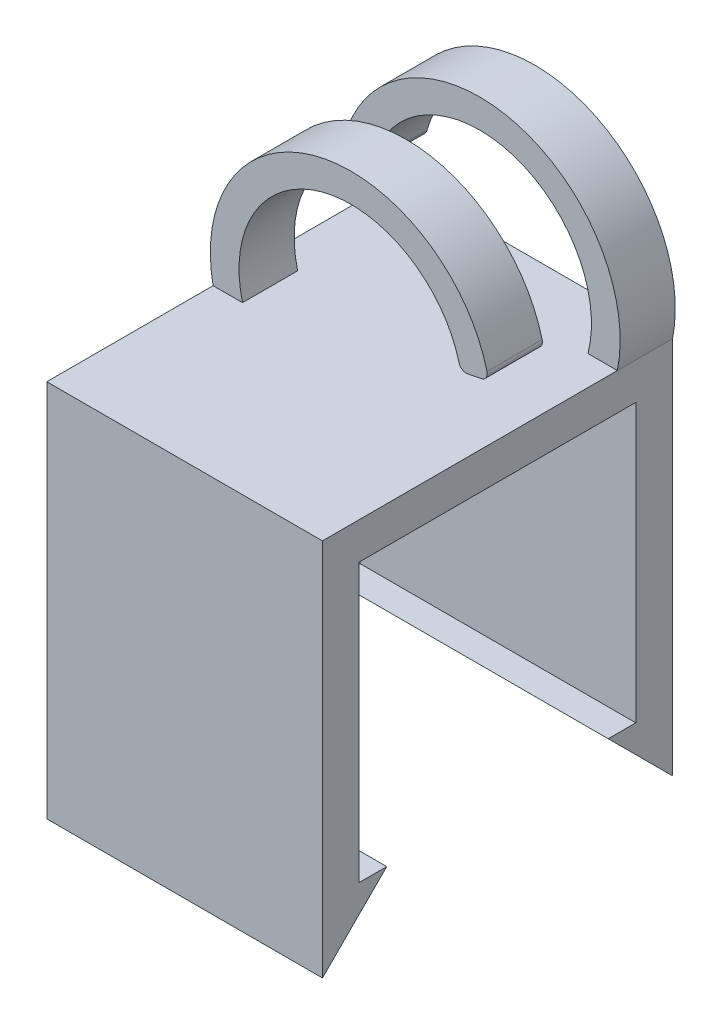
from build123d import *

# Parameters (mm, degrees)
SKETCH_1_W        = 15
SKETCH_1_H        = 2
EXTRUDE_1_DEPTH   = 15.1
EXTRUDE_1_2_DEPTH = 15.1
SKETCH_2_W        = 15
SKETCH_2_H        = 19.05
EXTRUDE_2_DEPTH   = 2
EXTRUDE_3_DEPTH   = 15
EXTRUDE_4_DEPTH   = 3
EXTRUDE_5_DEPTH   = 3


with BuildPart() as part:
    # 草图1 → 凸台-拉伸1 (new body)
    with BuildSketch(Plane(origin=(0, 0, 0), x_dir=(1, 0, 0), z_dir=(0, 1, 0))):
        with Locations((-8.12962963, 5.864814815)):
            Rectangle(SKETCH_1_W, SKETCH_1_H)
    extrude(amount=EXTRUDE_1_DEPTH)



with BuildPart() as body_2:
    # 草图1 → Extrude 1 2 (new body)
    with BuildSketch(Plane(origin=(0, 0, 0), x_dir=(1, 0, 0), z_dir=(0, 1, 0))):
        with Locations((-8.12962963, -11.185185185)):
            Rectangle(SKETCH_1_W, SKETCH_1_H)
    extrude(amount=EXTRUDE_1_2_DEPTH)


with BuildPart() as part_1:
    add(part.part)

    add(body_2.part)  # 凸台-拉伸2 merges body 2
    # 草图2 → 凸台-拉伸2 (add)
    with BuildSketch(Plane(origin=(0, 15.1, 0), x_dir=(1, 0, 0), z_dir=(0, 1, 0))):
        with Locations((-8.12962963, -2.660185185)):
            Rectangle(SKETCH_2_W, SKETCH_2_H)
    extrude(amount=EXTRUDE_2_DEPTH)

    # 草图3 → 凸台-拉伸3 (add)
    with BuildSketch(Plane.ZY.offset(15.62962963)):
        Polygon((-6.864814815, 0), (-3.364814815, 0), (-6.864814815, -3.5), align=None)
        Polygon((12.185185185, 0), (8.685185185, 0), (12.185185185, -3.5), align=None)
    extrude(amount=-EXTRUDE_3_DEPTH)

    # 草图5 → 凸台-拉伸4 (add)
    with BuildSketch(Plane(origin=(0, 0, -6.864814815), x_dir=(-1, 0, 0), z_dir=(0, 0, -1))):
        with BuildLine():
            Line((14.570760421, 19.888226158), (15.122171723, 19.998508419))
            ThreePointArc((15.122171723, 19.998508419), (15.449589497, 20.226176769), (15.506344599, 20.62090976))
            ThreePointArc((15.506344599, 20.62090976), (6.36809587, 26.042916016), (0.62962963, 17.1))
            Line((0.62962963, 17.1), (2.22962963, 17.1))
            ThreePointArc((2.22962963, 17.1), (6.557748265, 24.481257432), (13.991268777, 20.243528676))
            ThreePointArc((13.991268777, 20.243528676), (14.211351698, 19.952258552), (14.570760421, 19.888226158))
        make_face()
    extrude(amount=-EXTRUDE_4_DEPTH)

    # 草图7 → 凸台-拉伸5 (add)
    with BuildSketch(Plane.XY.offset(0.135185185)):
        with BuildLine():
            Line((-1.780026825, 19.869920561), (-1.032692548, 20.019387416))
            ThreePointArc((-1.032692548, 20.019387416), (-0.772321289, 20.199010756), (-0.723833364, 20.511591398))
            ThreePointArc((-0.723833364, 20.511591398), (-9.836075513, 26.055738893), (-15.62962963, 17.1))
            Line((-15.62962963, 17.1), (-14.02962963, 17.1))
            ThreePointArc((-14.02962963, 17.1), (-9.659485473, 24.492329005), (-2.245122699, 20.15967246))
            ThreePointArc((-2.245122699, 20.15967246), (-2.069982872, 19.922647762), (-1.780026825, 19.869920561))
        make_face()
    extrude(amount=EXTRUDE_5_DEPTH)


solid = part_1.part
